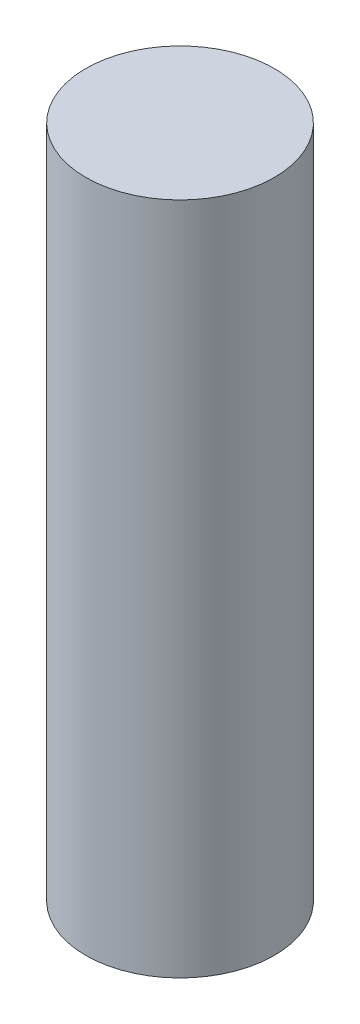
from build123d import *

# Parameters (mm, degrees)
ESQUISSE1_R        = 10.5
BOSS_EXTRU_1_DEPTH = 37.5


with BuildPart() as part:
    # Esquisse1 → Boss.-Extru.1 (new body, symmetric)
    with BuildSketch(Plane(origin=(0, 0, 0), x_dir=(1, 0, 0), z_dir=(0, 1, 0))):
        Circle(ESQUISSE1_R)
    extrude(amount=BOSS_EXTRU_1_DEPTH, both=True)


solid = part.part
